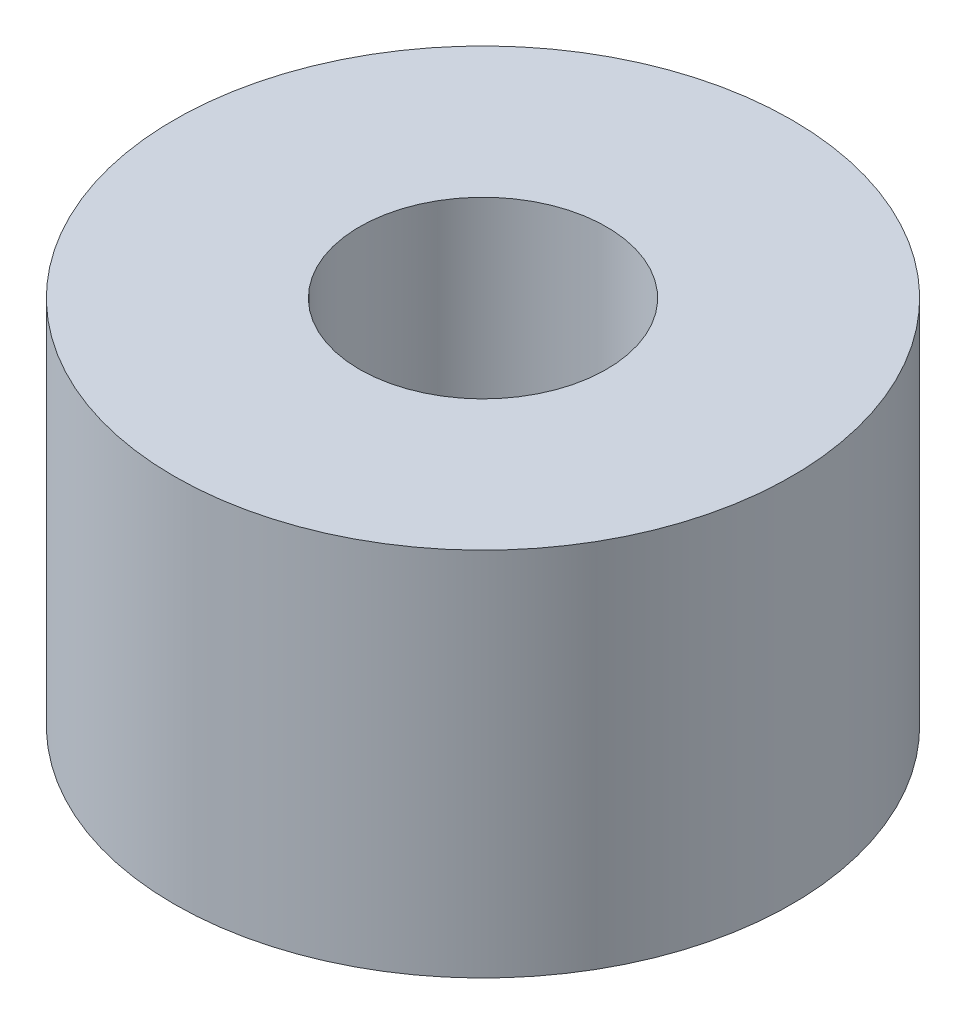
from build123d import *

# Parameters (mm, degrees)
SKETCH1_R           = 5
SKETCH1_R_2         = 2
BOSS_EXTRUDE1_DEPTH = 6


with BuildPart() as part:
    # Sketch1 → Boss-Extrude1 (new body)
    with BuildSketch(Plane(origin=(0, 0, 0), x_dir=(1, 0, 0), z_dir=(0, 1, 0))):
        Circle(SKETCH1_R)
        Circle(SKETCH1_R_2, mode=Mode.SUBTRACT)
    extrude(amount=BOSS_EXTRUDE1_DEPTH)


solid = part.part
